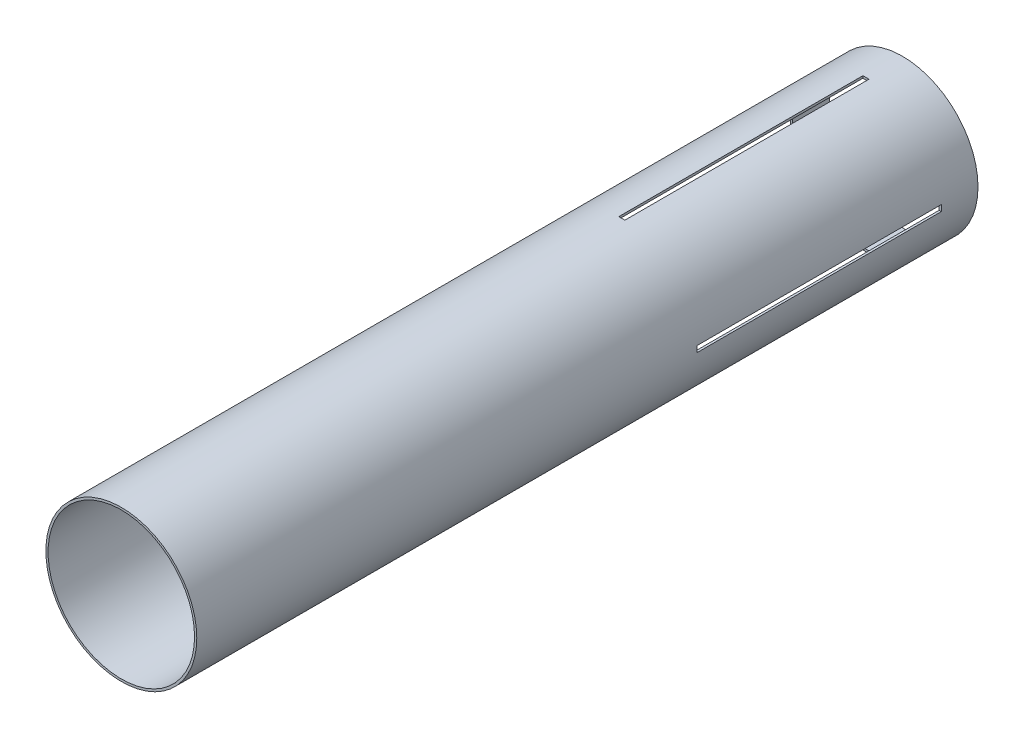
from build123d import *

# Parameters (mm, degrees)
SKETCH1_R           = 39.2557
SKETCH1_R_2         = 38.1
BOSS_EXTRUDE1_DEPTH = 203.2
SKETCH3_W           = 3.175
SKETCH3_H           = 127
CUT_EXTRUDE1_DEPTH  = 40.2557
CIRPATTERN1_COUNT   = 4


with BuildPart() as part:
    # Sketch1 → Boss-Extrude1 (new body, symmetric)
    with BuildSketch(Plane.XY):
        Circle(SKETCH1_R)
        Circle(SKETCH1_R_2, mode=Mode.SUBTRACT)
    extrude(amount=BOSS_EXTRUDE1_DEPTH, both=True)

    # Sketch3 → Cut-Extrude1 (cut, through all)
    with BuildSketch(Plane(origin=(0, 0, 0), x_dir=(1, 0, 0), z_dir=(0, 1, 0))):
        with Locations((0, 120.65)):
            Rectangle(SKETCH3_W, SKETCH3_H)
    cut_extrude1 = extrude(amount=CUT_EXTRUDE1_DEPTH, mode=Mode.SUBTRACT)

    # CirPattern1: Cut-Extrude1 ×4 about axis
    cirpattern1_axis = Axis((0, 0, 0), (0, 0, 1))
    for i in range(1, CIRPATTERN1_COUNT):
        add(cut_extrude1.rotate(cirpattern1_axis, i * 360 / CIRPATTERN1_COUNT), mode=Mode.SUBTRACT)


solid = part.part
